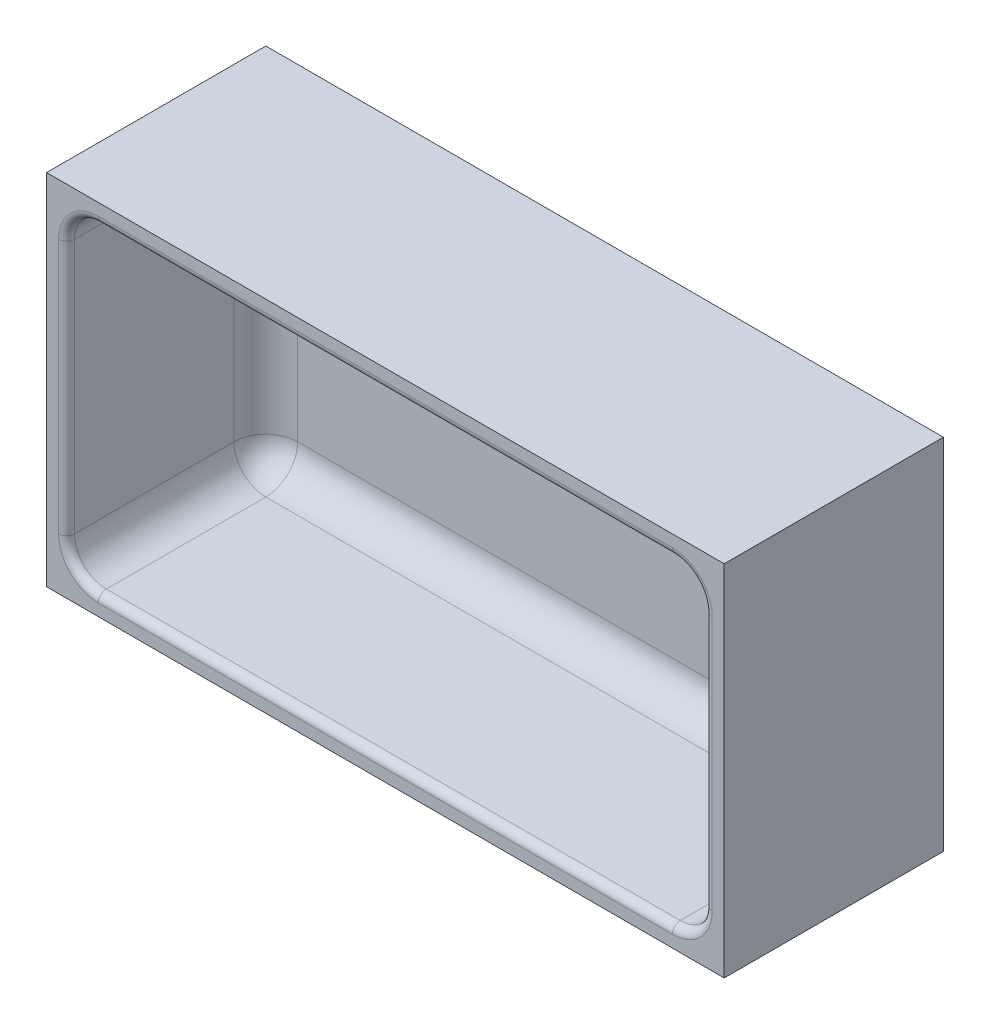
from build123d import *

# Parameters (mm, degrees)
IZIM1_W                     = 80
IZIM1_H                     = 160
Y_KSEKLIK_EKSTR_ZYON1_DEPTH = 5
IZIM1_3_W                   = 90
IZIM1_3_H                   = 170
IZIM1_3_W_2                 = 80
IZIM1_3_H_2                 = 160
Y_KSEKLIK_EKSTR_ZYON2_DEPTH = 55
RADYUS2_R                   = 8
RADYUS4_R                   = 2


with BuildPart() as part:
    # Çizim1 → Yükseklik-Ekstrüzyon1 (new body)
    with BuildSketch(Plane(origin=(0, 0, 0), x_dir=(0, 1, 0), z_dir=(0, 0, 1))):
        with Locations((45, 85)):
            Rectangle(IZIM1_W, IZIM1_H)
    extrude(amount=Y_KSEKLIK_EKSTR_ZYON1_DEPTH)

    # Çizim1<3> → Yükseklik-Ekstrüzyon2 (add)
    with BuildSketch(Plane(origin=(0, 0, 0), x_dir=(0, 1, 0), z_dir=(0, 0, 1))):
        with Locations((45, 85)):
            Rectangle(IZIM1_3_W, IZIM1_3_H)
        with Locations((45, 85)):
            Rectangle(IZIM1_3_W_2, IZIM1_3_H_2, mode=Mode.SUBTRACT)
    extrude(amount=Y_KSEKLIK_EKSTR_ZYON2_DEPTH)

    # Radyus2
    radyus2_edges = [part.edges().sort_by_distance(p)[0] for p in [
        (-5, 5, 30),
        (-5, 85, 30),
        (-165, 85, 30),
        (-165, 5, 30),
        (-5, 45, 5),
        (-85, 5, 5),
        (-85, 85, 5),
        (-165, 45, 5),
    ]]
    fillet(radyus2_edges, radius=RADYUS2_R)

    # Radyus4
    radyus4_edges = [part.edges().sort_by_distance(p)[0] for p in [
        (-162.656854249, 82.656854249, 55),
        (-7.343145751, 82.656854249, 55),
        (-7.343145751, 7.343145751, 55),
        (-162.656854249, 7.343145751, 55),
        (-85, 85, 55),
        (-5, 45, 55),
        (-85, 5, 55),
        (-165, 45, 55),
    ]]
    fillet(radyus4_edges, radius=RADYUS4_R)


solid = part.part
